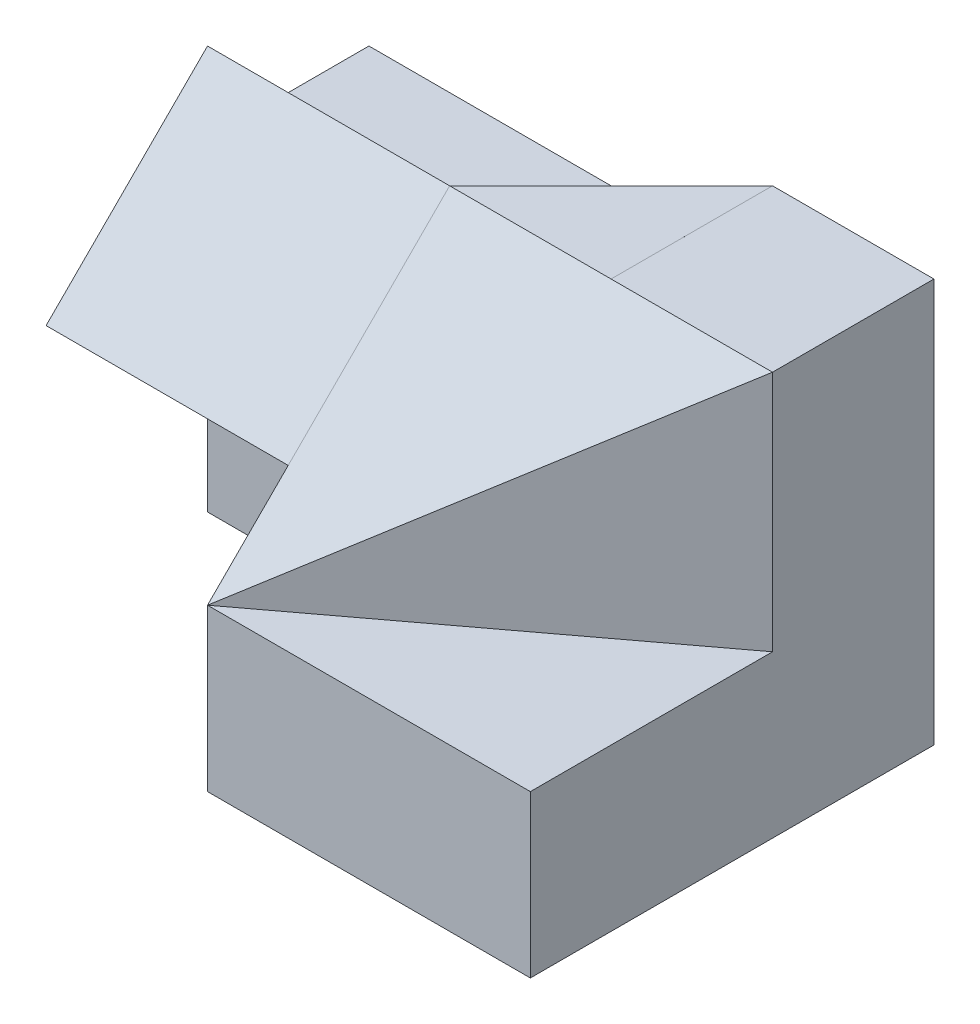
from build123d import *

# Parameters (mm, degrees)
SKETCH1_W            = 70
SKETCH1_H            = 50
BOSS_EXTRUDE1_DEPTH  = 50
SKETCH2_W            = 30
SKETCH2_H            = 10
CUT_EXTRUDE1_DEPTH   = 50
CUT_EXTRUDE2_DEPTH   = 91
SKETCH6_W            = 20
SKETCH6_H            = 30
CUT_EXTRUDE7_DEPTH   = 30
CUT_EXTRUDE11_DEPTH  = 30
CUT_EXTRUDE12_DEPTH  = 10
BOSS_EXTRUDE8_DEPTH  = 10
SKETCH17_W           = 20
SKETCH17_H           = 20
CUT_EXTRUDE14_DEPTH  = 0.0001
BOSS_EXTRUDE19_DEPTH = 30
BOSS_EXTRUDE20_DEPTH = 20
CUT_EXTRUDE15_DEPTH  = 20
CUT_EXTRUDE16_DEPTH  = 54
CUT_EXTRUDE17_DEPTH  = 54
BOSS_EXTRUDE28_DEPTH = 30
SKETCH28_W           = 30
SKETCH28_H           = 30
BOSS_EXTRUDE30_DEPTH = 31
SKETCH29_W           = 30
SKETCH29_H           = 30
CUT_EXTRUDE20_DEPTH  = 30
CUT_EXTRUDE21_DEPTH  = 30
CUT_EXTRUDE22_DEPTH  = 30
SKETCH32_W           = 20
SKETCH32_H           = 20
CUT_EXTRUDE23_DEPTH  = 0.0001
CUT_EXTRUDE39_DEPTH  = 0.0001


with BuildPart() as part:
    # Sketch1 → Boss-Extrude1 (new body)
    with BuildSketch(Plane.XY):
        with Locations((35, 25)):
            Rectangle(SKETCH1_W, SKETCH1_H)
    extrude(amount=BOSS_EXTRUDE1_DEPTH)

    # Sketch2 → Cut-Extrude1 (cut)
    with BuildSketch(Plane(origin=(0, 50, 0), x_dir=(1, 0, 0), z_dir=(0, 1, 0))):
        with Locations((15, -45)):
            Rectangle(SKETCH2_W, SKETCH2_H)
    extrude(amount=-CUT_EXTRUDE1_DEPTH, mode=Mode.SUBTRACT)

    # Sketch3 → Cut-Extrude2 (cut)
    with BuildSketch(Plane.ZY):
        Polygon((40, 50), (20, 50), (40, 30), align=None)
        Polygon((40, 50), (40, 30), (50, 20), (50, 50), align=None)
    extrude(amount=-CUT_EXTRUDE2_DEPTH, mode=Mode.SUBTRACT)

    # Sketch6 → Cut-Extrude7 (cut)
    with BuildSketch(Plane.ZY):
        with Locations((30, 15)):
            Rectangle(SKETCH6_W, SKETCH6_H)
    extrude(amount=-CUT_EXTRUDE7_DEPTH, mode=Mode.SUBTRACT)

    # Sketch10 → Cut-Extrude11 (cut)
    with BuildSketch(Plane.XY.offset(50)):
        Polygon((30, 20), (70, 20), (70, 50), (50, 50), (30, 30), align=None)
    extrude(amount=-CUT_EXTRUDE11_DEPTH, mode=Mode.SUBTRACT)

    # Sketch11 → Cut-Extrude12 (cut)
    with BuildSketch(Plane(origin=(0, 50, 0), x_dir=(1, 0, 0), z_dir=(0, 1, 0))):
        Polygon((0, 0), (0, -20), (30, -20), (50, 0), align=None)
    extrude(amount=-CUT_EXTRUDE12_DEPTH, mode=Mode.SUBTRACT)

    # Sketch12 → Boss-Extrude8 (add)
    with BuildSketch(Plane.ZY.offset(-30)):
        Polygon((20, 29.999), (20, 20), (20.001, 20), (50, 20), (40.001, 29.999), align=None)
        Polygon((20.001, 20), (20, 20), (20, 0), (50, 0), (50, 20), align=None)
    extrude(amount=-BOSS_EXTRUDE8_DEPTH)

    # Sketch17 → Cut-Extrude14 (cut)
    with BuildSketch(Plane(origin=(0, 50, 0), x_dir=(1, 0, 0), z_dir=(0, 1, 0))):
        with Locations((60, -10)):
            Rectangle(SKETCH17_W, SKETCH17_H)
    extrude(amount=-CUT_EXTRUDE14_DEPTH, mode=Mode.SUBTRACT)

    # Sketch18 → Boss-Extrude19 (add)
    with BuildSketch(Plane(origin=(0, 50, 0), x_dir=(1, 0, 0), z_dir=(0, 1, 0))):
        Polygon((50, 0), (30, -20), (30, -50), (50, -20), align=None)
    extrude(amount=-BOSS_EXTRUDE19_DEPTH)

    # Sketch19 → Boss-Extrude20 (add)
    with BuildSketch(Plane(origin=(34.8, 0, 46.4), x_dir=(-0.8, 0, 0.6), z_dir=(-0.6, 0, -0.8))):
        Polygon((6, 20), (-44, 20), (-44, 49.9999), (6, 50), align=None)
    extrude(amount=BOSS_EXTRUDE20_DEPTH)

    # Sketch21 → Cut-Extrude15 (cut)
    with BuildSketch(Plane(origin=(34.8, 0, 46.4), x_dir=(0.8, 0, -0.6), z_dir=(0.6, 0, 0.8))):
        Polygon((6.5, 27.5), (6.5, 20), (-6, 20), align=None)
    extrude(amount=CUT_EXTRUDE15_DEPTH, mode=Mode.SUBTRACT)

    # Sketch22 → Cut-Extrude16 (cut)
    with BuildSketch(Plane(origin=(8e-05, 49.999988, -6e-05), x_dir=(1, -1.6e-06, 0), z_dir=(1.6e-06, 1, -1.2e-06))):
        Polygon((29.99992, -25.00006), (29.99992, -50.00006), (17.99992, -34.00006), align=None)
    extrude(amount=-CUT_EXTRUDE16_DEPTH, mode=Mode.SUBTRACT)

    # Sketch23 → Cut-Extrude17 (cut)
    with BuildSketch(Plane(origin=(29.99992, -4.8e-05, 0), x_dir=(0, 0, 1), z_dir=(-1, 1.6e-06, 0))):
        Polygon((20, 50.000048), (50, 20.000048), (50, 50.000048), align=None)
    extrude(amount=-CUT_EXTRUDE17_DEPTH, mode=Mode.SUBTRACT)

    # Sketch27 → Boss-Extrude28 (add)
    with BuildSketch(Plane.ZY):
        Polygon((20, 50), (20, 30), (40, 30), align=None)
    extrude(amount=-BOSS_EXTRUDE28_DEPTH)

    # Sketch28 → Boss-Extrude30 (add)
    with BuildSketch(Plane.ZY):
        with Locations((35, 15)):
            Rectangle(SKETCH28_W, SKETCH28_H)
    extrude(amount=-BOSS_EXTRUDE30_DEPTH)

    # Sketch29 → Cut-Extrude20 (cut)
    with BuildSketch(Plane.ZY):
        with Locations((35, 15)):
            Rectangle(SKETCH29_W, SKETCH29_H)
    extrude(amount=-CUT_EXTRUDE20_DEPTH, mode=Mode.SUBTRACT)

    # Sketch30 → Cut-Extrude21 (cut)
    with BuildSketch(Plane(origin=(31, 0, 0), x_dir=(0, 0, -1), z_dir=(1, 0, 0))):
        Polygon((-39.9999984, 30), (-50, 19.999999199), (-50, 30), align=None)
    extrude(amount=-CUT_EXTRUDE21_DEPTH, mode=Mode.SUBTRACT)

    # Sketch31 → Cut-Extrude22 (cut)
    with BuildSketch(Plane(origin=(0, 20, 0), x_dir=(1, 0, 0), z_dir=(0, 1, 0))):
        Polygon((31, -49.25), (30, -50), (31, -50), align=None)
    extrude(amount=CUT_EXTRUDE22_DEPTH, mode=Mode.SUBTRACT)

    # Sketch32 → Cut-Extrude23 (cut)
    with BuildSketch(Plane(origin=(8e-05, 50.000048, 0), x_dir=(1, -1.6e-06, 0), z_dir=(-1.6e-06, -1, 0))):
        with Locations((59.99992, 10)):
            Rectangle(SKETCH32_W, SKETCH32_H)
    extrude(amount=CUT_EXTRUDE23_DEPTH, mode=Mode.SUBTRACT)

    # Sketch33 → Cut-Extrude39 (cut)
    with BuildSketch(Plane(origin=(0, 50, 0), x_dir=(1, 0, 0), z_dir=(0, 1, 0))):
        Polygon((30, -50), (30, -20.000018003), (49.999976, -20.000036), align=None)
    extrude(amount=-CUT_EXTRUDE39_DEPTH, mode=Mode.SUBTRACT)


solid = part.part
